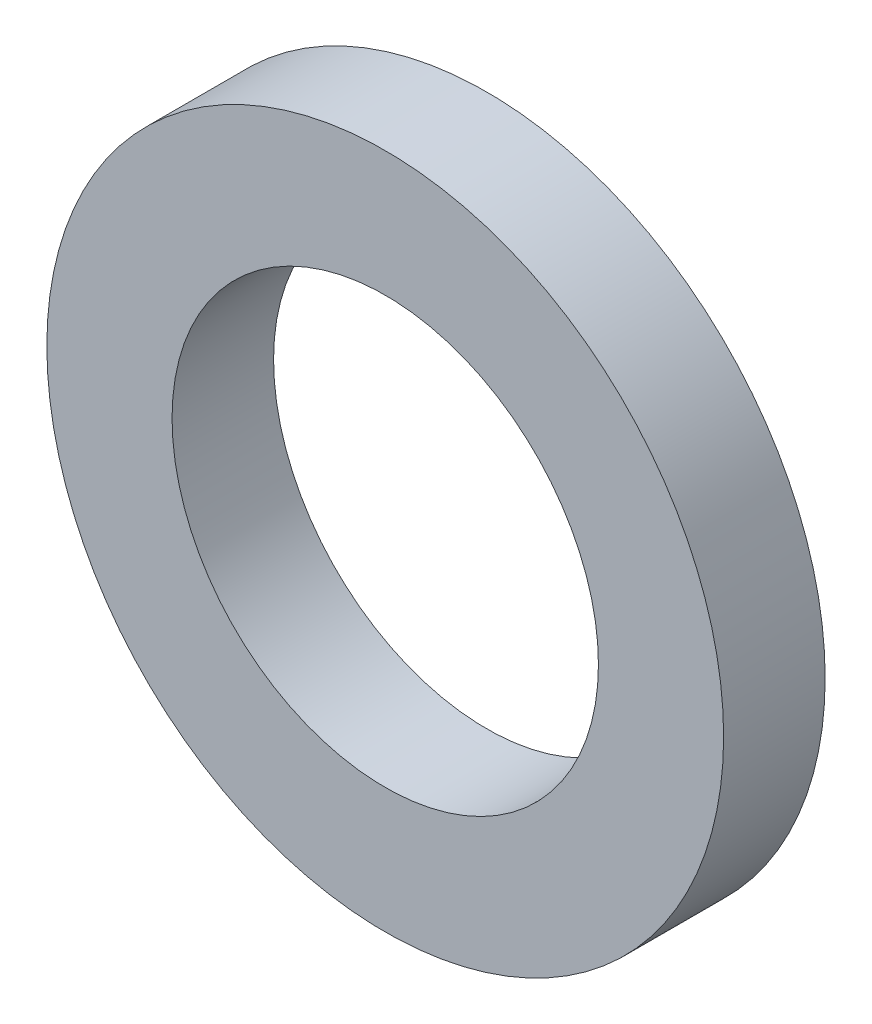
from build123d import *

# Parameters (mm, degrees)
SKETCH1_R           = 10
SKETCH1_R_2         = 6.3
BOSS_EXTRUDE1_DEPTH = 3


with BuildPart() as part:
    # Sketch1 → Boss-Extrude1 (new body)
    with BuildSketch(Plane.XY):
        Circle(SKETCH1_R)
        Circle(SKETCH1_R_2, mode=Mode.SUBTRACT)
    extrude(amount=BOSS_EXTRUDE1_DEPTH)


solid = part.part
